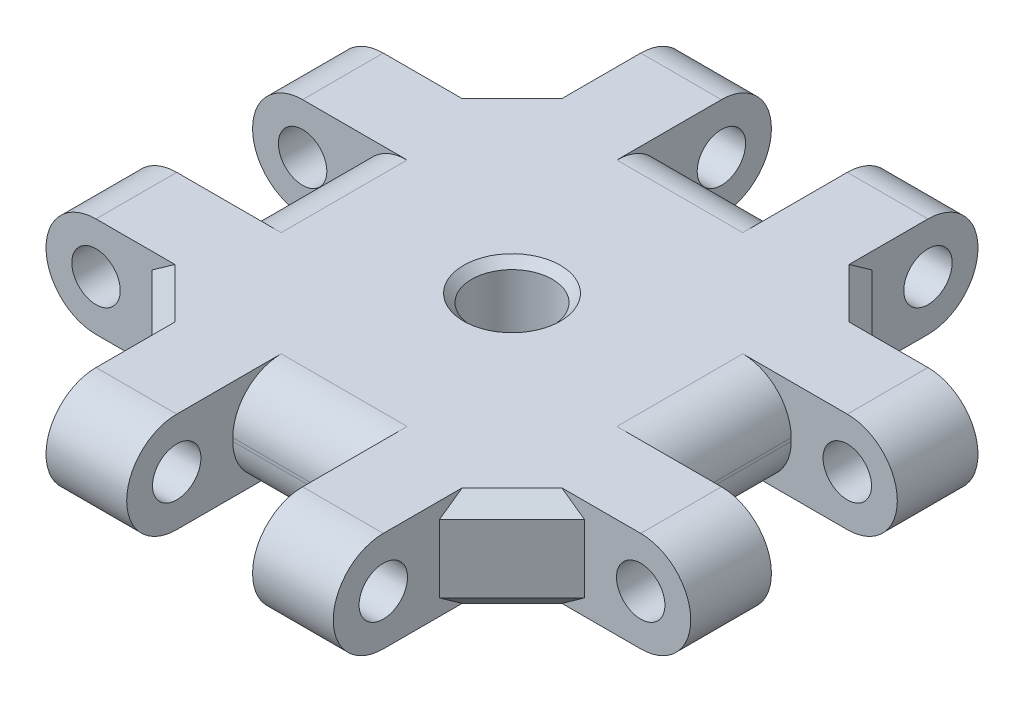
from build123d import *

# Parameters (mm, degrees)
SKETCH1_R           = 2.5
BOSS_EXTRUDE1_DEPTH = 3.1
CUT_EXTRUDE1_START  = -30.25
SKETCH2_R           = 1.5
CUT_EXTRUDE1_DEPTH  = 42.7
CIRPATTERN1_COUNT   = 4
FILLET1_R           = 3
CHAMFER1_SIZE       = 1
CHAMFER3_SIZE       = 0.5


with BuildPart() as part:
    # Sketch1 → Boss-Extrude1 (new body, symmetric)
    with BuildSketch(Plane(origin=(0, 0, 0), x_dir=(1, 0, 0), z_dir=(0, 1, 0))):
        Polygon((-8.9, -13.4), (-8.9, -20.35), (-3.9, -20.35), (-3.9, -13.4), (3.9, -13.4), (3.9, -20.35), (8.9, -20.35), (8.9, -13.4), (13.4, -8.9), (20.35, -8.9), (20.35, -3.9), (13.4, -3.9), (13.4, 3.9), (20.35, 3.9), (20.35, 8.9), (13.4, 8.9), (8.9, 13.4), (8.9, 20.35), (3.9, 20.35), (3.9, 13.4), (-3.9, 13.4), (-3.9, 20.35), (-8.9, 20.35), (-8.9, 13.4), (-13.4, 8.9), (-20.35, 8.9), (-20.35, 3.9), (-13.4, 3.9), (-13.4, -3.9), (-20.35, -3.9), (-20.35, -8.9), (-13.4, -8.9), align=None)
        Circle(SKETCH1_R, mode=Mode.SUBTRACT)
    extrude(amount=BOSS_EXTRUDE1_DEPTH, both=True)

    # Sketch2 → Cut-Extrude1 (cut)
    with BuildSketch(Plane.ZY.offset(8.9).offset(CUT_EXTRUDE1_START)):
        with Locations((16.875, 0)):
            Circle(SKETCH2_R)
        with BuildLine():
            Line((16.875, 3.1), (20.35, 3.1))
            Line((20.35, 3.1), (20.35, -3.1))
            Line((20.35, -3.1), (16.875, -3.1))
            ThreePointArc((16.875, -3.1), (19.975, 0), (16.875, 3.1))
        make_face()
    cut_extrude1 = extrude(amount=CUT_EXTRUDE1_DEPTH, mode=Mode.SUBTRACT)

    # CirPattern1: Cut-Extrude1 ×4 about axis
    cirpattern1_axis = Axis((0, 3.1, 0), (0, 1, 0))
    for i in range(1, CIRPATTERN1_COUNT):
        add(cut_extrude1.rotate(cirpattern1_axis, i * 360 / CIRPATTERN1_COUNT), mode=Mode.SUBTRACT)

    # Fillet1
    fillet1_edges = [part.edges().sort_by_distance(p)[0] for p in [
        (-13.4, 3.1, 0),
        (0, 3.1, 13.4),
        (-13.4, -3.1, 0),
        (0, -3.1, -13.4),
        (13.4, -3.1, 0),
        (0, -3.1, 13.4),
        (13.4, 3.1, 0),
        (0, 3.1, -13.4),
    ]]
    fillet(fillet1_edges, radius=FILLET1_R)

    # Chamfer1
    chamfer1_edges = [part.edges().sort_by_distance(p)[0] for p in [
        (-11.15, 3.1, -11.15),
        (-11.15, -3.1, -11.15),
        (11.15, -3.1, -11.15),
        (11.15, 3.1, 11.15),
        (11.15, -3.1, 11.15),
        (-11.15, -3.1, 11.15),
        (-11.15, 3.1, 11.15),
        (11.15, 3.1, -11.15),
    ]]
    chamfer(chamfer1_edges, length=CHAMFER1_SIZE)

    # Chamfer3
    chamfer3_edges = [part.edges().sort_by_distance(p)[0] for p in [
        (-2.5, -3.1, 0),
        (-2.5, 3.1, 0),
    ]]
    chamfer(chamfer3_edges, length=CHAMFER3_SIZE)


solid = part.part
